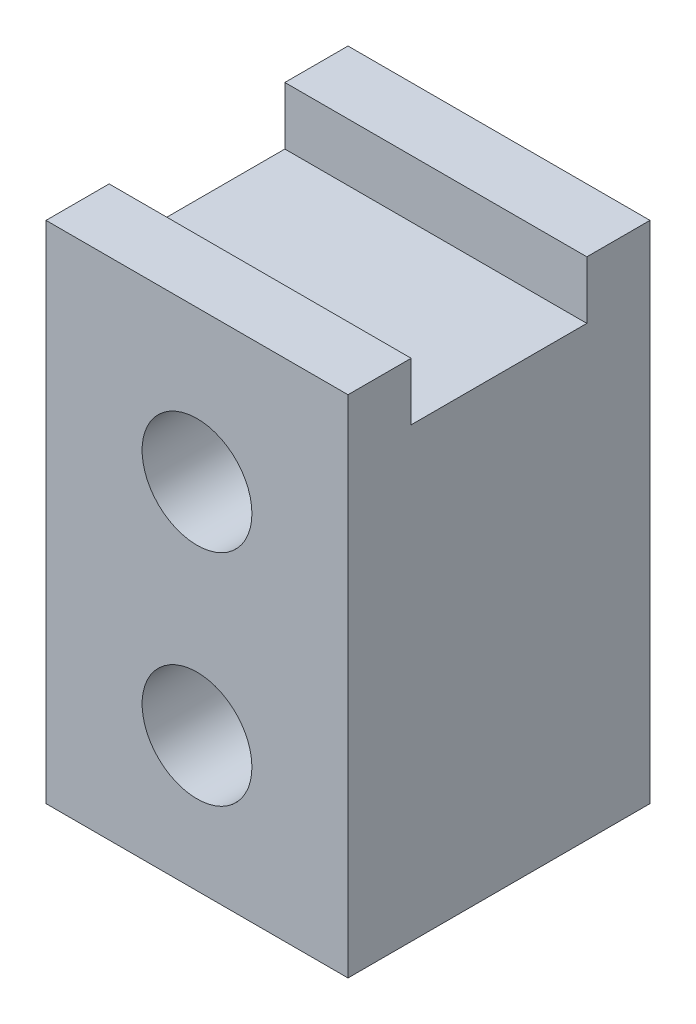
from build123d import *

# Parameters (mm, degrees)
CROQUIS1_W              = 55
CROQUIS1_H              = 92
SALIENTE_EXTRUIR1_DEPTH = 55
CROQUIS2_R              = 10
CORTAR_EXTRUIR1_DEPTH   = 56
CROQUIS3_W              = 32
CROQUIS3_H              = 10.5
CORTAR_EXTRUIR2_DEPTH   = 55


with BuildPart() as part:
    # Croquis1 → Saliente-Extruir1 (new body)
    with BuildSketch(Plane.XY):
        Rectangle(CROQUIS1_W, CROQUIS1_H)
    extrude(amount=SALIENTE_EXTRUIR1_DEPTH)

    # Croquis2 → Cortar-Extruir1 (cut, through all)
    with BuildSketch(Plane.XY):
        with Locations((0, 18.5)):
            Circle(CROQUIS2_R)
        with Locations((0, -21.5)):
            Circle(CROQUIS2_R)
    extrude(amount=CORTAR_EXTRUIR1_DEPTH, mode=Mode.SUBTRACT)

    # Croquis3 → Cortar-Extruir2 (cut)
    with BuildSketch(Plane.ZY.offset(27.5)):
        with Locations((27.5, 40.75)):
            Rectangle(CROQUIS3_W, CROQUIS3_H)
    extrude(amount=-CORTAR_EXTRUIR2_DEPTH, mode=Mode.SUBTRACT)


solid = part.part
